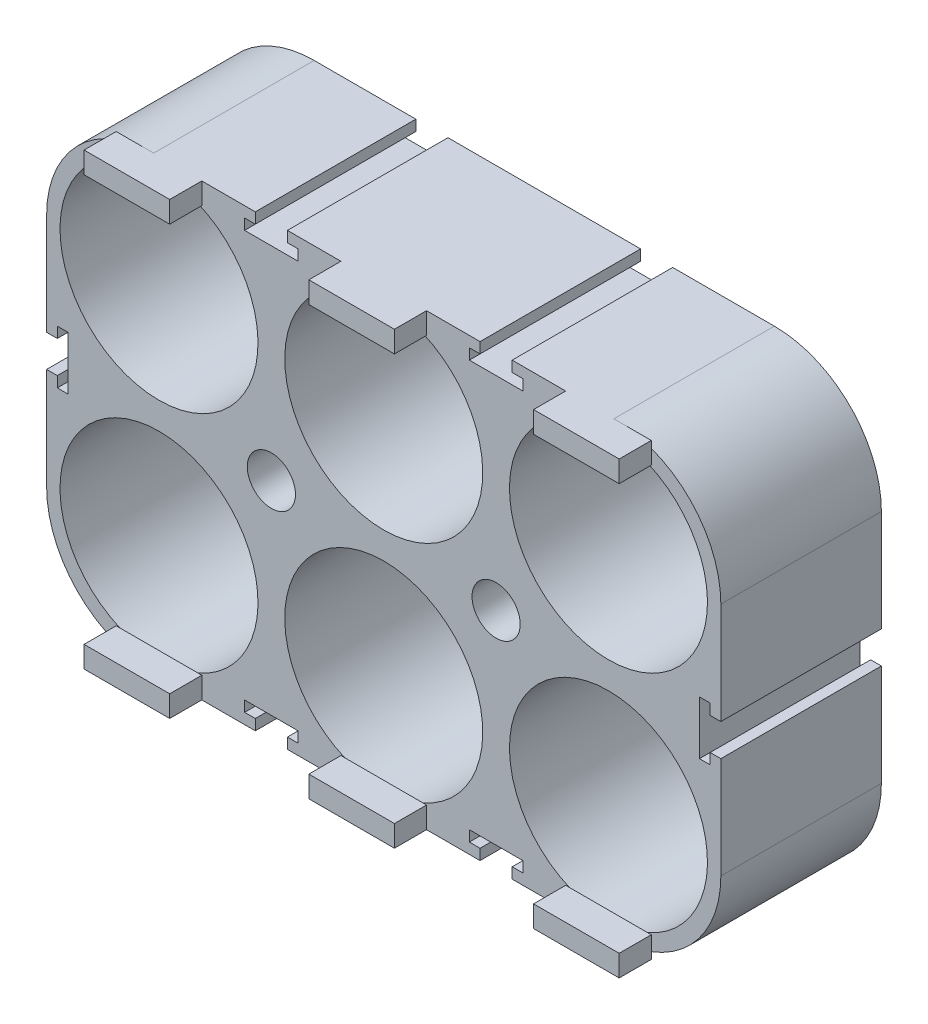
from build123d import *

# Parameters (mm, degrees)
SKETCH1_W            = 63
SKETCH1_H            = 42
SKETCH1_R            = 9.25
BOSS_EXTRUDE1_DEPTH  = 15
FILLET1_R            = 10
SKETCH3_W            = 8
SKETCH3_H            = 2
BOSS_EXTRUDE2_DEPTH  = 7
M4_CLEARANCE_HOLE1_D = 4.5
CUT_EXTRUDE1_DEPTH   = 23
SKETCH7_W            = 116.08326012
SKETCH7_H            = 87.262251834
CUT_EXTRUDE2_DEPTH   = 4


with BuildPart() as part:
    # Sketch1 → Boss-Extrude1 (new body)
    with BuildSketch(Plane.XY):
        with Locations((31.5, 21)):
            Rectangle(SKETCH1_W, SKETCH1_H)
        with Locations((10.5, 31.5)):
            Circle(SKETCH1_R, mode=Mode.SUBTRACT)
        with Locations((10.5, 10.5)):
            Circle(SKETCH1_R, mode=Mode.SUBTRACT)
        with Locations((52.5, 31.5)):
            Circle(SKETCH1_R, mode=Mode.SUBTRACT)
        with Locations((52.5, 10.5)):
            Circle(SKETCH1_R, mode=Mode.SUBTRACT)
        with Locations((31.5, 31.5)):
            Circle(SKETCH1_R, mode=Mode.SUBTRACT)
        with Locations((31.5, 10.5)):
            Circle(SKETCH1_R, mode=Mode.SUBTRACT)
    extrude(amount=BOSS_EXTRUDE1_DEPTH)

    # Fillet1
    fillet1_edges = [part.edges().sort_by_distance(p)[0] for p in [
        (0, 42, 7.5),
        (63, 42, 7.5),
        (63, 0, 7.5),
        (0, 0, 7.5),
    ]]
    fillet(fillet1_edges, radius=FILLET1_R)

    # Sketch3 → Boss-Extrude2 (add)
    with BuildSketch(Plane.XY.offset(15)):
        with Locations((31.5, 1)):
            Rectangle(SKETCH3_W, SKETCH3_H)
        with Locations((52.5, 1)):
            Rectangle(SKETCH3_W, SKETCH3_H)
        with Locations((10.5, 1)):
            Rectangle(SKETCH3_W, SKETCH3_H)
        with Locations((10.5, 41)):
            Rectangle(SKETCH3_W, SKETCH3_H)
        with Locations((31.5, 41)):
            Rectangle(SKETCH3_W, SKETCH3_H)
        with Locations((52.5, 41)):
            Rectangle(SKETCH3_W, SKETCH3_H)
    extrude(amount=BOSS_EXTRUDE2_DEPTH)

    # M4 Clearance Hole1 (through all)
    with Locations(Plane.XY.offset(15)):
        with Locations((21, 21), (42, 21)):
            Hole(M4_CLEARANCE_HOLE1_D / 2)

    # Sketch6 → Cut-Extrude1 (cut, through all)
    with BuildSketch(Plane(origin=(0, 0, 0), x_dir=(-1, 0, 0), z_dir=(0, 0, -1))):
        Polygon((-40.5, 41), (-39.5, 41), (-39.5, 40), (-44.5, 40), (-44.5, 41), (-43.5, 41), (-43.5, 42), (-40.5, 42), align=None)
        Polygon((-19.5, 41), (-18.5, 41), (-18.5, 40), (-23.5, 40), (-23.5, 41), (-22.5, 41), (-22.5, 42), (-19.5, 42), align=None)
        Polygon((-44.5, 1), (-43.5, 1), (-43.5, 0), (-40.5, 0), (-40.5, 1), (-39.5, 1), (-39.5, 2), (-44.5, 2), align=None)
        Polygon((-18.5, 2), (-18.5, 1), (-19.5, 1), (-19.5, 0), (-22.5, 0), (-22.5, 1), (-23.5, 1), (-23.5, 2), align=None)
        Polygon((-62, 19.5), (-63, 19.5), (-63, 22.5), (-62, 22.5), (-62, 23.5), (-61, 23.5), (-61, 18.5), (-62, 18.5), align=None)
        Polygon((-1, 22.5), (-1, 23.5), (-2, 23.5), (-2, 18.5), (-1, 18.5), (-1, 19.5), (0, 19.5), (0, 22.5), align=None)
    extrude(amount=-CUT_EXTRUDE1_DEPTH, mode=Mode.SUBTRACT)

    # Sketch7 → Cut-Extrude2 (cut)
    with BuildSketch(Plane.XY.offset(22)):
        with Locations((31.5, 10.5)):
            Rectangle(SKETCH7_W, SKETCH7_H)
    extrude(amount=-CUT_EXTRUDE2_DEPTH, mode=Mode.SUBTRACT)


solid = part.part
